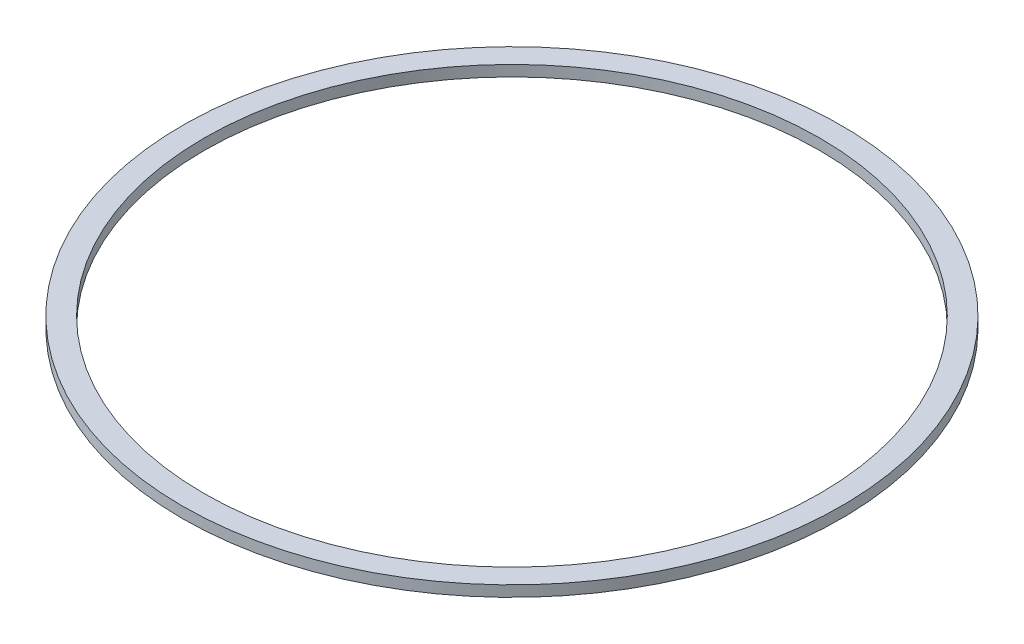
from build123d import *

# Parameters (mm, degrees)
SKETCH1_R            = 75.925
SKETCH1_R_2          = 70.925
BOSS_EXTRUDE1_DEPTH  = 2.5
CUT_SWEEP1_PROFILE_R = 1.5


with BuildPart() as part:
    # Sketch1 → Boss-Extrude1 (new body)
    with BuildSketch(Plane(origin=(0, 0, 0), x_dir=(1, 0, 0), z_dir=(0, 1, 0))):
        Circle(SKETCH1_R)
        Circle(SKETCH1_R_2, mode=Mode.SUBTRACT)
    extrude(amount=-BOSS_EXTRUDE1_DEPTH)

    # Cut-Sweep1: sweep along a path in Sketch2
    with BuildLine(Plane.XZ.offset(2.5)) as cut_sweep1_path:
        CenterArc((0, 0), 73.425, 0, 360)
    # Cut-Sweep1 profile (on start of the path) → Cut-Sweep1 (sweep, cut)
    with BuildSketch(Plane(origin=(73.425, -2.5, 0), x_dir=(1, 0, 0), z_dir=(0, 0, 1))):
        Circle(CUT_SWEEP1_PROFILE_R)
    sweep(path=cut_sweep1_path.line, mode=Mode.SUBTRACT)


solid = part.part
